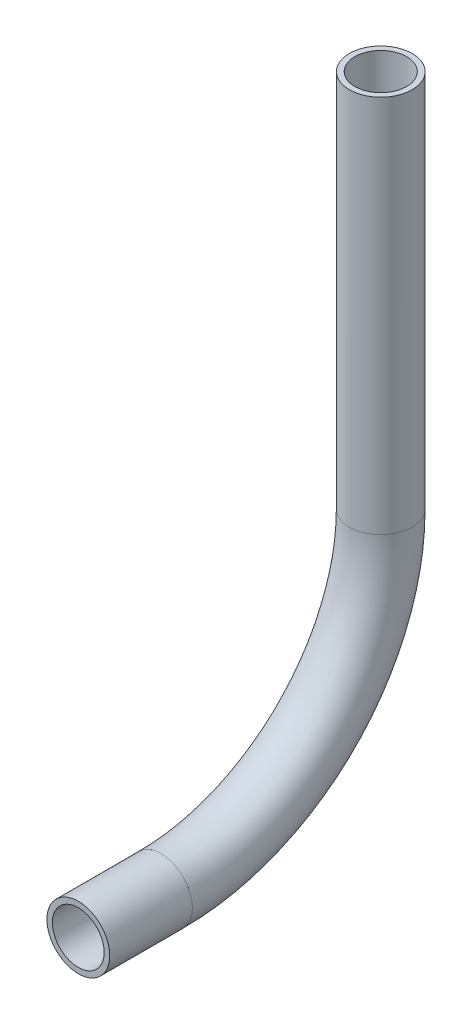
from build123d import *

# Parameters (mm, degrees)
SKETCH11_R                = 3.175
SKETCH11_R_2              = 2.6162
PIPE_0_5_SCH_40_1_DEPTH   = 8.358456741
SKETCH11_ON_SEGMENT_2_R   = 3.175
SKETCH11_ON_SEGMENT_2_R_2 = 2.6162
PIPE_0_5_SCH_40_1_2_ANGLE = 90
SKETCH11_ON_SEGMENT_3_R   = 3.175
SKETCH11_ON_SEGMENT_3_R_2 = 2.6162
PIPE_0_5_SCH_40_1_3_DEPTH = 38.312746142


with BuildPart() as part:
    # Sketch11 → Pipe 0.5 SCH 40(1) (new body)
    with BuildSketch(Plane(origin=(0, 600.034535067, 303.144625759), x_dir=(0, 1, 0), z_dir=(0, 0, -1))):
        Circle(SKETCH11_R)
        Circle(SKETCH11_R_2, mode=Mode.SUBTRACT)
    extrude(amount=PIPE_0_5_SCH_40_1_DEPTH)


with BuildPart() as body_2:
    # Sketch11 on segment 2 (carried to the start of arc 2) → Pipe 0.5 SCH 40_1 2 (revolve)
    with BuildSketch(Plane(origin=(0, 600.034535067, 294.786169018), x_dir=(0, 1, 0), z_dir=(0, 0, -1))):
        Circle(SKETCH11_ON_SEGMENT_2_R)
        Circle(SKETCH11_ON_SEGMENT_2_R_2, mode=Mode.SUBTRACT)
    revolve(axis=Axis((0, 622.259535067, 294.786169018), (1, 0, 0)), revolution_arc=PIPE_0_5_SCH_40_1_2_ANGLE)


with BuildPart() as body_3:
    # Sketch11 on segment 3 (carried to segment 3) → Pipe 0.5 SCH 40_1 3 (new body)
    with BuildSketch(Plane(origin=(0, 622.259535067, 272.561169018), x_dir=(0, 0, 1), z_dir=(0, 1, 0))):
        Circle(SKETCH11_ON_SEGMENT_3_R)
        Circle(SKETCH11_ON_SEGMENT_3_R_2, mode=Mode.SUBTRACT)
    extrude(amount=PIPE_0_5_SCH_40_1_3_DEPTH)


solid = Compound([part.part, body_2.part, body_3.part])
